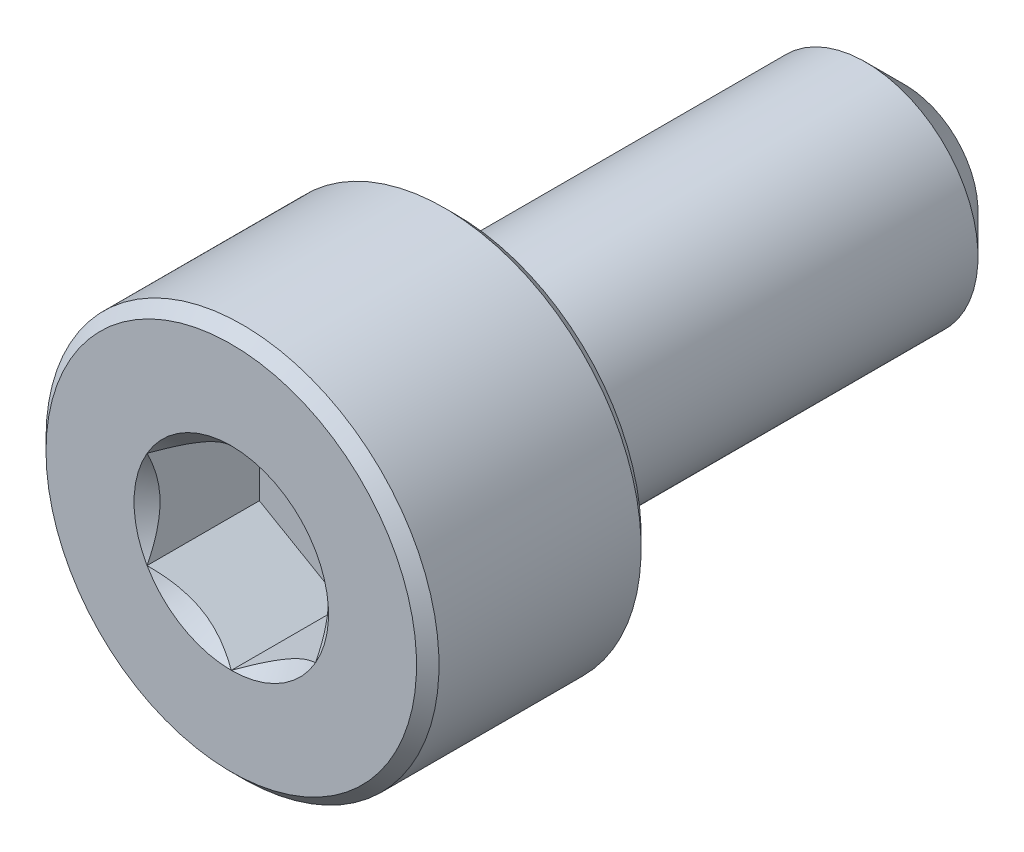
from build123d import *

# Parameters (mm, degrees)
CUT_EXTRUDE1_START = -2
CUT_EXTRUDE1_DEPTH = 2
SKETCH4_R          = 1.732050808
CUT_EXTRUDE2_DEPTH = 0.5
CUT_EXTRUDE2_TAPER = 45


with BuildPart() as part:
    # Sketch2 → Revolve1 (revolve)
    with BuildSketch(Plane(origin=(0, 0, 0), x_dir=(0, 0, -1), z_dir=(1, 0, 0))):
        Polygon((-5.8, 3.5), (-2.2, 3.5), (-2, 3.3), (-2, 2), (5.3, 2), (6, 1.3), (6, 0), (-6, 0), (-6, 3.3), align=None)
    revolve(axis=Axis((0, 0, -6), (0, 0, 1)))

    # Sketch3 → Cut-Extrude1 (cut)
    with BuildSketch(Plane.XY.offset(6).offset(CUT_EXTRUDE1_START)):
        Polygon((0, 1.732050808), (-1.5, 0.866025404), (-1.5, -0.866025404), (0, -1.732050808), (1.5, -0.866025404), (1.5, 0.866025404), align=None)
    extrude(amount=CUT_EXTRUDE1_DEPTH, mode=Mode.SUBTRACT)

    # Sketch4 → Cut-Extrude2 (cut)
    with BuildSketch(Plane.XY.offset(6)):
        Circle(SKETCH4_R)
    extrude(amount=-CUT_EXTRUDE2_DEPTH, taper=CUT_EXTRUDE2_TAPER, mode=Mode.SUBTRACT)


solid = part.part
